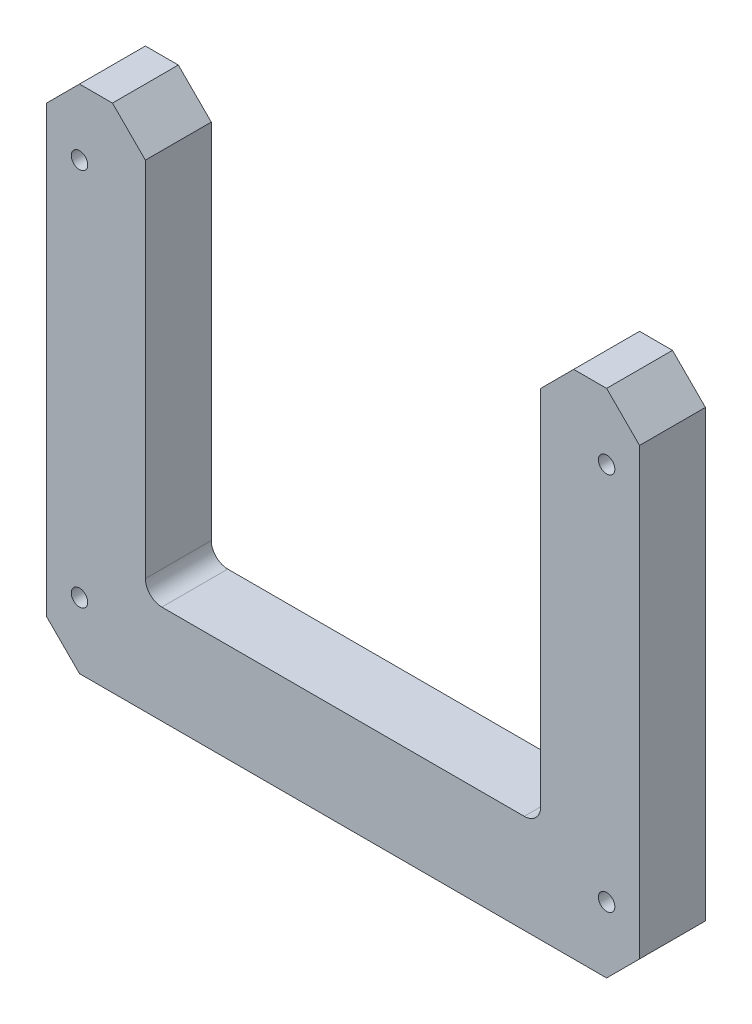
from build123d import *

# Parameters (mm, degrees)
BOSS_EXTRUDE1_DEPTH = 12.7
FILLET1_R           = 3.175
CHAMFER1_SIZE       = 6.35
HOLE1_D             = 3.175
HOLE1_DEPTH         = 31.75
HOLE1_CSINK_D       = 10.16
HOLE1_CSINK_ANGLE   = 82
HOLE1_TIP           = 0.953866233


with BuildPart() as part:
    # Sketch1 → Boss-Extrude1 (new body)
    with BuildSketch(Plane.XY):
        Polygon((-231.027465963, 69.04320968), (-231.027465963, -10.33179032), (-154.827465963, -10.33179032), (-154.827465963, 69.04320968), (-135.777465963, 69.04320968), (-135.777465963, -29.38179032), (-250.077465963, -29.38179032), (-250.077465963, 69.04320968), align=None)
    extrude(amount=BOSS_EXTRUDE1_DEPTH)

    # Fillet1
    fillet1_edges = [part.edges().sort_by_distance(p)[0] for p in [
        (-231.027465963, -10.33179032, 6.35),
        (-154.827465963, -10.33179032, 6.35),
    ]]
    fillet(fillet1_edges, radius=FILLET1_R)

    # Chamfer1
    chamfer1_edges = [part.edges().sort_by_distance(p)[0] for p in [
        (-231.027465963, 69.04320968, 6.35),
        (-154.827465963, 69.04320968, 6.35),
        (-135.777465963, 69.04320968, 6.35),
        (-135.777465963, -29.38179032, 6.35),
        (-250.077465963, -29.38179032, 6.35),
        (-250.077465963, 69.04320968, 6.35),
    ]]
    chamfer(chamfer1_edges, length=CHAMFER1_SIZE)

    # Hole1
    with Locations(Plane(origin=(-124.004465969, -215.287141225, -12.7), x_dir=(-1, 0, 0), z_dir=(0, 0, -1))):
        with Locations((113.649999994, 128.807623392), (113.649999994, 23.940956725), (-94.599999994, 161.374290059), (94.599999994, 161.374290059), (0, 161.374290059), (0, 193.124290059), (0, 440.553783621), (0, 301.970350905), (40.979166666, 301.970350905), (166.795833328, 301.970350905), (207.774999994, 440.553783621), (207.774999994, 333.02141023), (207.774999994, 225.48903684), (207.774999994, 137.424290059), (207.774999994, 10.424290059), (-207.774999994, 10.424290059), (-207.774999994, 137.424290059), (-207.774999994, 225.48903684), (-207.774999994, 333.02141023), (-207.774999994, 440.553783621), (-166.795833328, 301.970350905), (-40.979166666, 301.970350905), (-113.649999994, 23.940956725), (-113.649999994, 128.807623392), (119.722999994, 198.605350905), (119.722999994, 271.630350905), (18.122999994, 198.605350905), (18.122999994, 271.630350905)):
            CounterSinkHole(HOLE1_D / 2, HOLE1_CSINK_D / 2, depth=HOLE1_DEPTH, counter_sink_angle=HOLE1_CSINK_ANGLE)
            with Locations((0, 0, -(HOLE1_DEPTH + HOLE1_TIP / 2))):  # 118° drill point
                Cone(0, HOLE1_D / 2, HOLE1_TIP, mode=Mode.SUBTRACT)


solid = part.part
